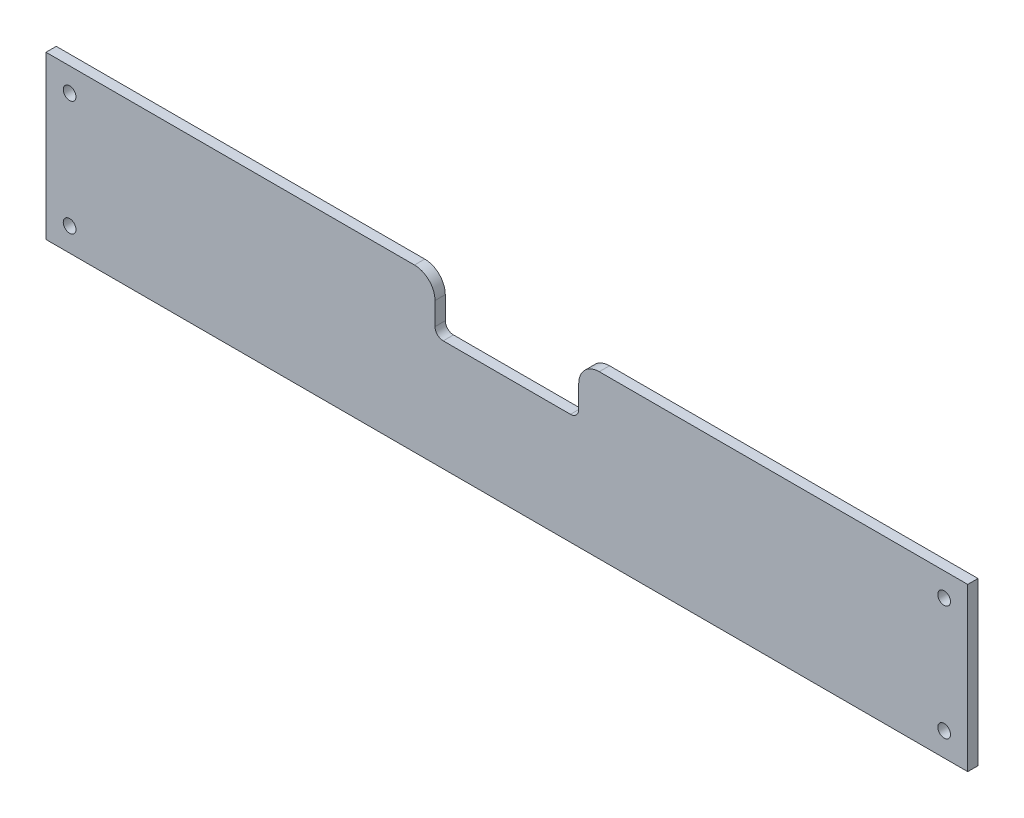
from build123d import *

# Parameters (mm, degrees)
SKETCH_F_R                   = 3.1
ESTRUSIONE_ESTRUSIONE1_DEPTH = 5


with BuildPart() as part:
    # Sketch f → Estrusione-Estrusione1 (new body)
    with BuildSketch(Plane.XY):
        with BuildLine():
            Line((0, 0), (0, 79))
            Line((0, 79), (179.5, 79))
            ThreePointArc((179.5, 79), (186.571067812, 76.071067812), (189.5, 69))
            Line((189.5, 69), (189.5, 58))
            ThreePointArc((189.5, 58), (190.671572875, 55.171572875), (193.5, 54))
            Line((193.5, 54), (255.5, 54))
            ThreePointArc((255.5, 54), (258.328427125, 55.171572875), (259.5, 58))
            Line((259.5, 58), (259.5, 69))
            ThreePointArc((259.5, 69), (262.428932188, 76.071067812), (269.5, 79))
            Line((269.5, 79), (449, 79))
            Line((449, 79), (449, 0))
            Line((449, 0), (0, 0))
        make_face()
        with Locations((11.5, 67.5)):
            Circle(SKETCH_F_R, mode=Mode.SUBTRACT)
        with Locations((437.5, 67.5)):
            Circle(SKETCH_F_R, mode=Mode.SUBTRACT)
        with Locations((11.5, 11.5)):
            Circle(SKETCH_F_R, mode=Mode.SUBTRACT)
        with Locations((437.5, 11.5)):
            Circle(SKETCH_F_R, mode=Mode.SUBTRACT)
    extrude(amount=ESTRUSIONE_ESTRUSIONE1_DEPTH)


solid = part.part
